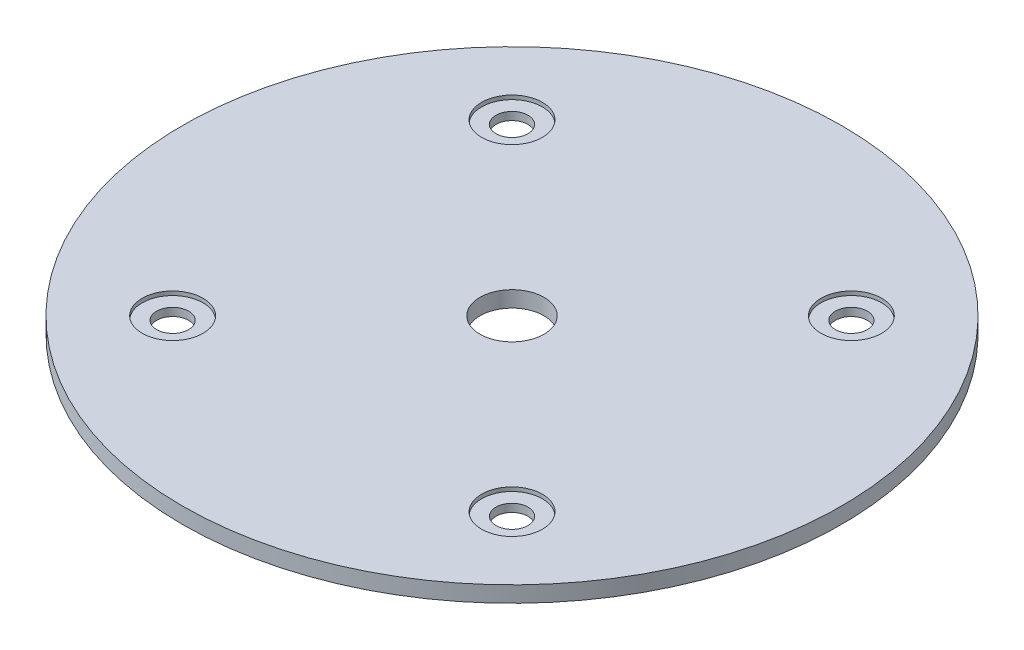
from build123d import *

# Parameters (mm, degrees)
SKETCH2_R                   = 65.405
BOSS_EXTRUDE1_DEPTH         = 1.5875
F_1_4_0_25_DIAMETER_HOLE1_D = 6.35
F_1_2_0_5_DIAMETER_HOLE1_D  = 12.7
SKETCH10_R                  = 6.0325
CUT_EXTRUDE1_DEPTH          = 0.79375


with BuildPart() as part:
    # Sketch2 → Boss-Extrude1 (new body, symmetric)
    with BuildSketch(Plane(origin=(0, 0, 0), x_dir=(1, 0, 0), z_dir=(0, 1, 0))):
        Circle(SKETCH2_R)
    extrude(amount=BOSS_EXTRUDE1_DEPTH, both=True)

    # 1/4 (0.25) Diameter Hole1 (through all)
    with Locations(Plane(origin=(0, 1.5875, 0), x_dir=(1, 0, 0), z_dir=(0, 1, 0))):
        with Locations((-33.675960454, -33.675960454), (-33.675960454, 33.675960454), (33.675960454, 33.675960454), (33.675960454, -33.675960454)):
            Hole(F_1_4_0_25_DIAMETER_HOLE1_D / 2)

    # 1/2 (0.5) Diameter Hole1 (through all)
    with Locations(Plane(origin=(0, 1.5875, 0), x_dir=(1, 0, 0), z_dir=(0, 1, 0))):
        with Locations((0, 0)):
            Hole(F_1_2_0_5_DIAMETER_HOLE1_D / 2)

    # Sketch10 → Cut-Extrude1 (cut)
    with BuildSketch(Plane(origin=(0, 1.5875, 0), x_dir=(1, 0, 0), z_dir=(0, 1, 0))):
        with Locations((-33.675960454, 33.675960454)):
            Circle(SKETCH10_R)
        with Locations((33.675960454, 33.675960454)):
            Circle(SKETCH10_R)
        with Locations((33.675960454, -33.675960454)):
            Circle(SKETCH10_R)
        with Locations((-33.675960454, -33.675960454)):
            Circle(SKETCH10_R)
    cut_extrude1 = extrude(amount=-CUT_EXTRUDE1_DEPTH, mode=Mode.SUBTRACT)

    # Mirror1: Cut-Extrude1 across plane
    add(cut_extrude1.mirror(Plane.ZX), mode=Mode.SUBTRACT)


solid = part.part
